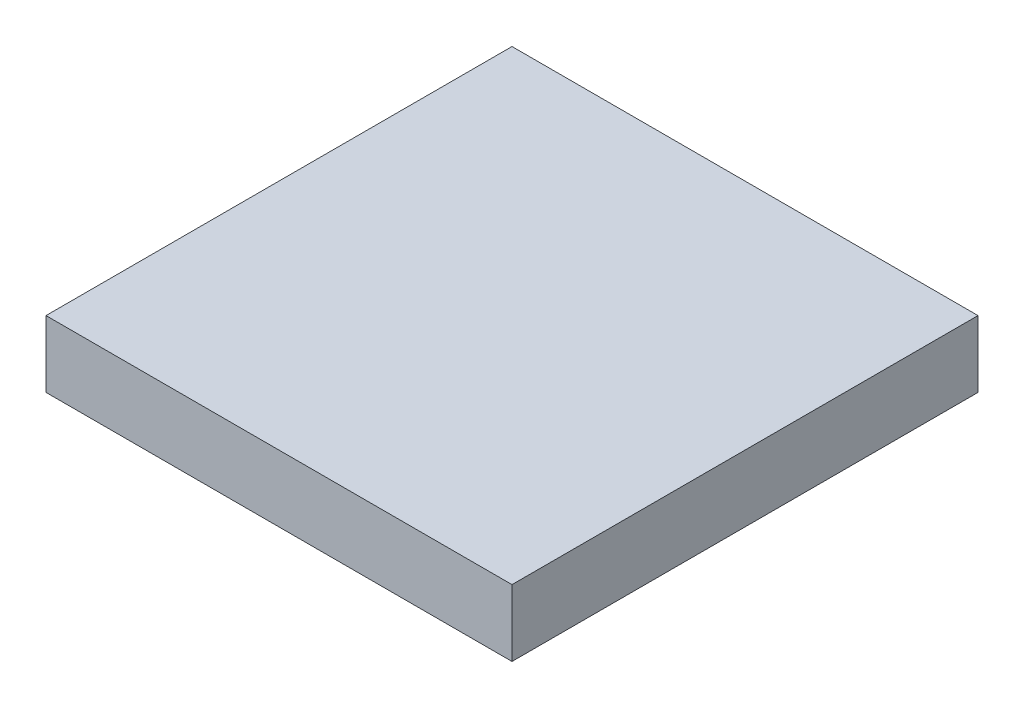
from build123d import *

# Parameters (mm, degrees)
SKETCH1_W           = 70
SKETCH1_H           = 70
BOSS_EXTRUDE1_DEPTH = 10


with BuildPart() as part:
    # Sketch1 → Boss-Extrude1 (new body)
    with BuildSketch(Plane(origin=(0, 0, 0), x_dir=(1, 0, 0), z_dir=(0, 1, 0))):
        Rectangle(SKETCH1_W, SKETCH1_H)
    extrude(amount=BOSS_EXTRUDE1_DEPTH)


solid = part.part
